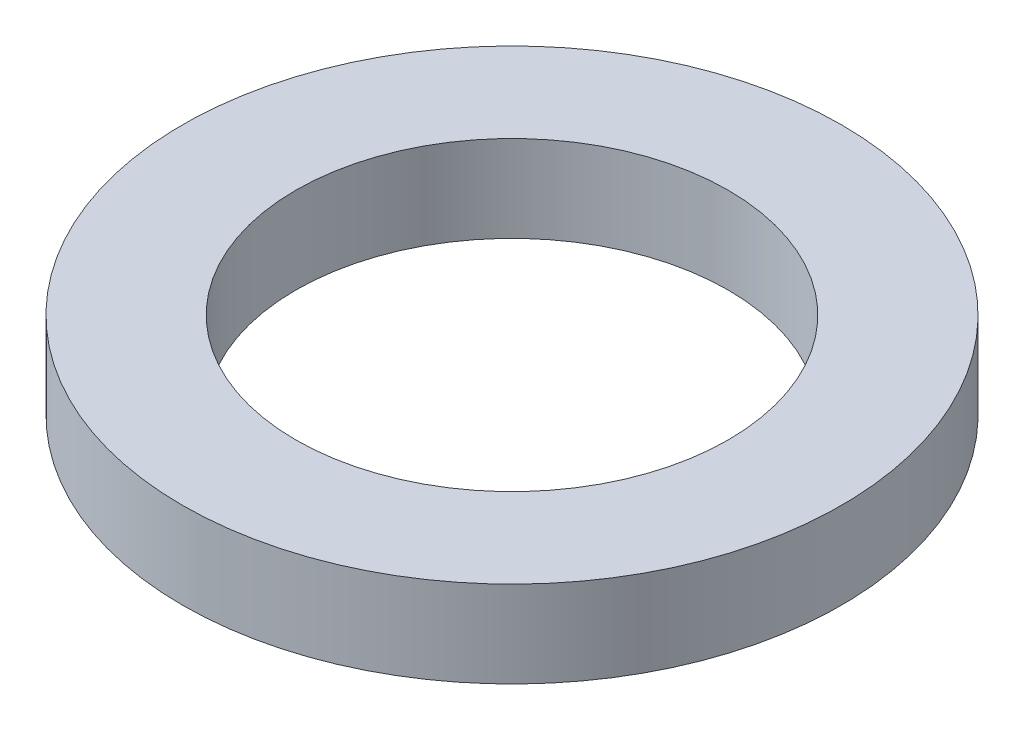
from build123d import *

# Parameters (mm, degrees)
SKETCH_1_W = 3.275
SKETCH_1_H = 2.5


with BuildPart() as part:
    # 草图1 → 旋转1 (revolve)
    with BuildSketch(Plane.XY, mode=Mode.PRIVATE) as revolve_1_sk:
        with Locations((7.8875, 1.25)):
            Rectangle(SKETCH_1_W, SKETCH_1_H)
    revolve(revolve_1_sk.sketch.rotate(Axis((0, 77.144142266, 0), (0, -1, 0)), 90), axis=Axis((0, 77.144142266, 0), (0, -1, 0)))  # turned: the seam where the file's is


solid = part.part
